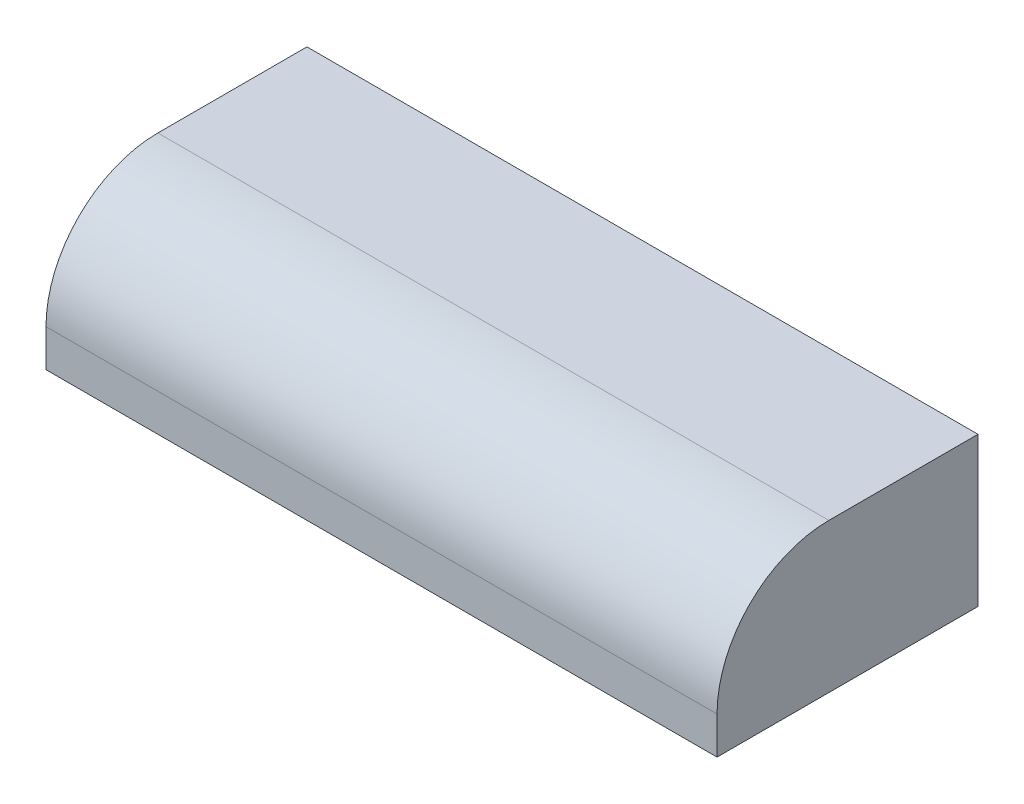
from build123d import *

# Parameters (mm, degrees)
SKETCH1_W           = 355.6
SKETCH1_H           = 203.2
BOSS_EXTRUDE1_DEPTH = 914.4
FILLET1_R           = 152.4


with BuildPart() as part:
    # Sketch1 → Boss-Extrude1 (new body)
    with BuildSketch(Plane(origin=(0, 0, 0), x_dir=(0, 0, -1), z_dir=(1, 0, 0))):
        with Locations((177.8, 101.6)):
            Rectangle(SKETCH1_W, SKETCH1_H)
    extrude(amount=BOSS_EXTRUDE1_DEPTH)

    # Fillet1
    fillet1_edges = [part.edges().sort_by_distance(p)[0] for p in [
        (457.2, 203.2, 0),
    ]]
    fillet(fillet1_edges, radius=FILLET1_R)


solid = part.part
